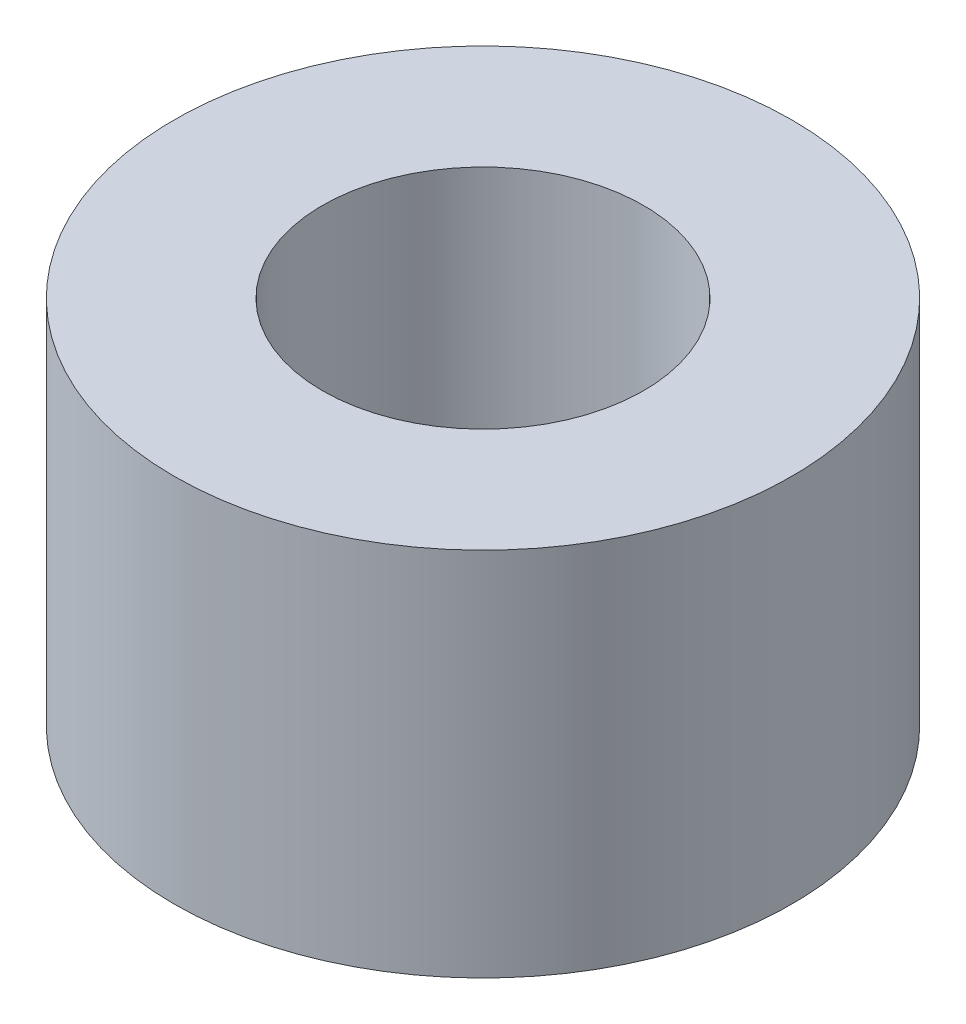
from build123d import *

# Parameters (mm, degrees)
ESQUISSE1_R      = 12.5
ESQUISSE1_R_2    = 6.5
EXTRUSION1_DEPTH = 15


with BuildPart() as part:
    # Esquisse1 → Extrusion1 (new body)
    with BuildSketch(Plane(origin=(0, 0, 0), x_dir=(1, 0, 0), z_dir=(0, 1, 0))):
        Circle(ESQUISSE1_R)
        Circle(ESQUISSE1_R_2, mode=Mode.SUBTRACT)
    extrude(amount=EXTRUSION1_DEPTH)


solid = part.part
